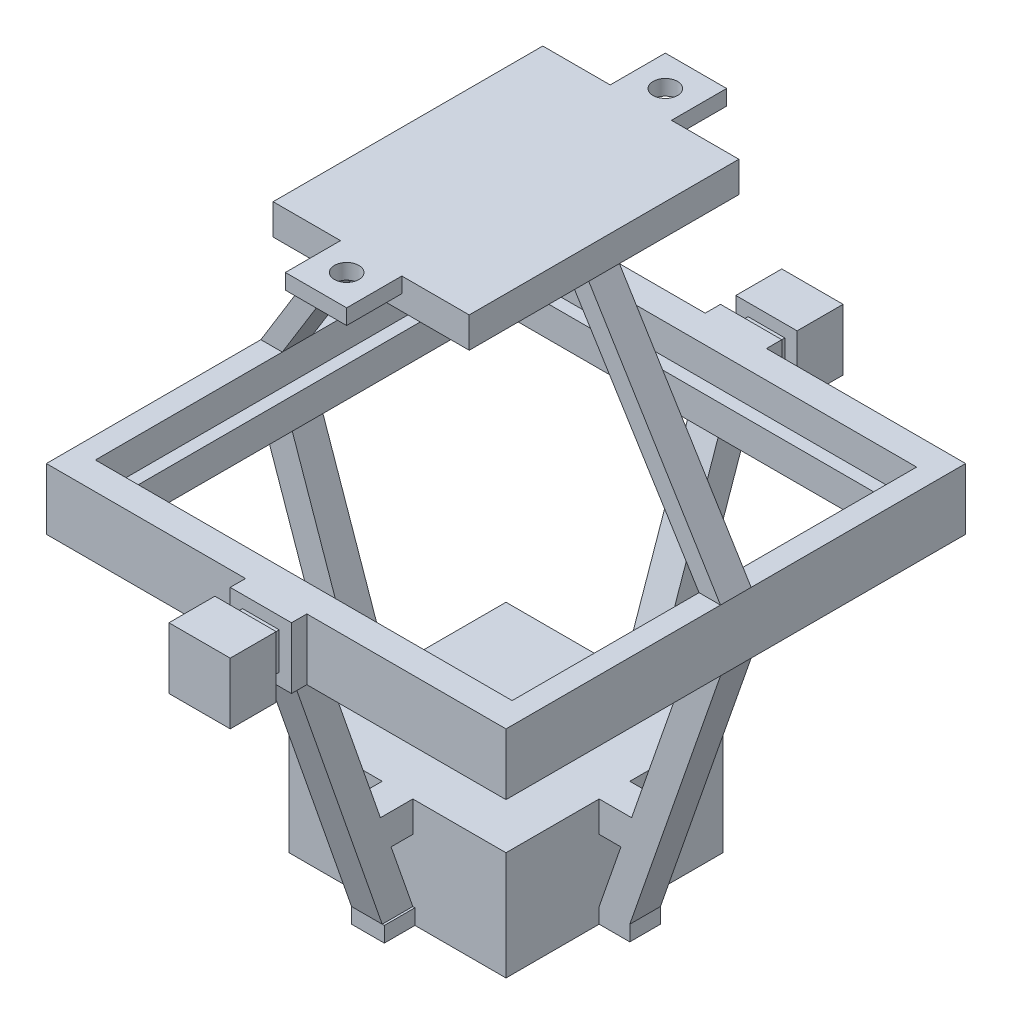
from build123d import *

# Parameters (mm, degrees)
SKETCH2_W                   = 75
SKETCH2_H                   = 75
BOSS_EXTRUDE1_DEPTH         = 5
SKETCH2_2_W                 = 75
SKETCH2_2_H                 = 75
BOSS_EXTRUDE2_DEPTH         = 5
SKETCH4_W                   = 68
SKETCH4_H                   = 66
CUT_EXTRUDE1_DEPTH          = 5
SKETCH5_W                   = 64
SKETCH5_H                   = 62
CUT_EXTRUDE2_DEPTH          = 5
SKETCH6_W                   = 10
SKETCH6_H                   = 10
BOSS_EXTRUDE3_DEPTH         = 2.5
SKETCH7_W                   = 6
SKETCH7_H                   = 6
BOSS_EXTRUDE4_DEPTH         = 2.5
SKETCH8_W                   = 10
SKETCH8_H                   = 10
BOSS_EXTRUDE5_DEPTH         = 7.5
SKETCH9_W                   = 10
SKETCH9_H                   = 10
BOSS_EXTRUDE6_DEPTH         = 2.5
SKETCH10_W                  = 6
SKETCH10_H                  = 6
BOSS_EXTRUDE7_DEPTH         = 2.5
SKETCH11_W                  = 10
SKETCH11_H                  = 10
BOSS_EXTRUDE8_DEPTH         = 7.5
SKETCH14_W                  = 35.4
SKETCH14_H                  = 35.4
BOSS_EXTRUDE9_DEPTH         = 17.7
SKETCH15_W                  = 25.4
SKETCH15_H                  = 25.4
CUT_EXTRUDE3_DEPTH          = 12.7
SKETCH32_R                  = 3
CUT_EXTRUDE6_DEPTH          = 5
SKETCH16_W                  = 32
SKETCH16_H                  = 44
BOSS_EXTRUDE10_DEPTH        = 5
SKETCH18_W                  = 10
SKETCH18_H                  = 9
BOSS_EXTRUDE12_DEPTH        = 2.5
BOSS_EXTRUDE13_DEPTH        = 2.5
BOSS_EXTRUDE14_DEPTH        = 2.5
SKETCH31_R                  = 2
CHARGER_SUPPORT_HOLES_DEPTH = 2.5
SKETCH27_W                  = 5
SKETCH27_H                  = 5
SKETCH27_W_2                = 5.344431893
EYEBOLT_BOLT_SUPPORTS_DEPTH = 2.5
BOSS_EXTRUDE15_DEPTH        = 2.5
BOSS_EXTRUDE16_DEPTH        = 2.5
BOSS_EXTRUDE17_DEPTH        = 2.5
BOSS_EXTRUDE18_DEPTH        = 2.5
SKETCH33_W                  = 6.3
SKETCH33_H                  = 5
SKETCH33_W_2                = 5
SKETCH33_H_2                = 6.3
EYEBOLT_MINI_SUPPORTS_DEPTH = 5


with BuildPart() as part:
    # Sketch2 → Boss-Extrude1 (new body)
    with BuildSketch(Plane(origin=(0, 0, 0), x_dir=(1, 0, 0), z_dir=(0, 1, 0))):
        Rectangle(SKETCH2_W, SKETCH2_H)
    extrude(amount=BOSS_EXTRUDE1_DEPTH)

    # Sketch2_2 → Boss-Extrude2 (add)
    with BuildSketch(Plane(origin=(0, 0, 0), x_dir=(1, 0, 0), z_dir=(0, 1, 0))):
        Rectangle(SKETCH2_2_W, SKETCH2_2_H)
    extrude(amount=-BOSS_EXTRUDE2_DEPTH)

    # Sketch4 → Cut-Extrude1 (cut)
    with BuildSketch(Plane(origin=(0, 5, 0), x_dir=(1, 0, 0), z_dir=(0, 1, 0))):
        Rectangle(SKETCH4_W, SKETCH4_H)
    extrude(amount=-CUT_EXTRUDE1_DEPTH, mode=Mode.SUBTRACT)

    # Sketch5 → Cut-Extrude2 (cut)
    with BuildSketch(Plane(origin=(0, 0, 0), x_dir=(1, 0, 0), z_dir=(0, 1, 0))):
        Rectangle(SKETCH5_W, SKETCH5_H)
    extrude(amount=-CUT_EXTRUDE2_DEPTH, mode=Mode.SUBTRACT)

    # Sketch6 → Boss-Extrude3 (add)
    with BuildSketch(Plane.XY.offset(37.5)):
        Rectangle(SKETCH6_W, SKETCH6_H)
    extrude(amount=BOSS_EXTRUDE3_DEPTH)

    # Sketch7 → Boss-Extrude4 (add)
    with BuildSketch(Plane.XY.offset(40)):
        Rectangle(SKETCH7_W, SKETCH7_H)
    extrude(amount=BOSS_EXTRUDE4_DEPTH)

    # Sketch8 → Boss-Extrude5 (add)
    with BuildSketch(Plane.XY.offset(42.5)):
        Rectangle(SKETCH8_W, SKETCH8_H)
    extrude(amount=BOSS_EXTRUDE5_DEPTH)

    # Sketch9 → Boss-Extrude6 (add)
    with BuildSketch(Plane(origin=(0, 0, -37.5), x_dir=(-1, 0, 0), z_dir=(0, 0, -1))):
        Rectangle(SKETCH9_W, SKETCH9_H)
    extrude(amount=BOSS_EXTRUDE6_DEPTH)

    # Sketch10 → Boss-Extrude7 (add)
    with BuildSketch(Plane(origin=(0, 0, -40), x_dir=(-1, 0, 0), z_dir=(0, 0, -1))):
        Rectangle(SKETCH10_W, SKETCH10_H)
    extrude(amount=BOSS_EXTRUDE7_DEPTH)

    # Sketch11 → Boss-Extrude8 (add)
    with BuildSketch(Plane(origin=(0, 0, -42.5), x_dir=(-1, 0, 0), z_dir=(0, 0, -1))):
        Rectangle(SKETCH11_W, SKETCH11_H)
    extrude(amount=BOSS_EXTRUDE8_DEPTH)



with BuildPart() as body_2:
    # Sketch14 → Boss-Extrude9 (new body)
    with BuildSketch(Plane(origin=(0, -50, 0), x_dir=(1, 0, 0), z_dir=(0, 1, 0))):
        Rectangle(SKETCH14_W, SKETCH14_H)
    extrude(amount=BOSS_EXTRUDE9_DEPTH)

    # Sketch15 → Cut-Extrude3 (cut)
    with BuildSketch(Plane.XZ.offset(50)):
        Rectangle(SKETCH15_W, SKETCH15_H)
    extrude(amount=-CUT_EXTRUDE3_DEPTH, mode=Mode.SUBTRACT)

    # Sketch32 → Cut-Extrude6 (cut)
    with BuildSketch(Plane(origin=(0, -32.3, 0), x_dir=(1, 0, 0), z_dir=(0, 1, 0))):
        Circle(SKETCH32_R)
    extrude(amount=-CUT_EXTRUDE6_DEPTH, mode=Mode.SUBTRACT)

    # Sketch27 → Eyebolt Bolt Supports (add)
    with BuildSketch(Plane(origin=(0, -50, 0), x_dir=(-1, 0, 0), z_dir=(0, -1, 0))):
        with Locations((-20.2, 0)):
            Rectangle(SKETCH27_W, SKETCH27_H)
        with Locations((20.2, 0)):
            Rectangle(SKETCH27_W, SKETCH27_H)
        with Locations((-0.172215947, -20.2)):
            Rectangle(SKETCH27_W_2, SKETCH27_H)
        with Locations((0, 20.2)):
            Rectangle(SKETCH27_W, SKETCH27_H)
    extrude(amount=-EYEBOLT_BOLT_SUPPORTS_DEPTH)


with BuildPart() as body_3:
    # Sketch16 → Boss-Extrude10 (new body)
    with BuildSketch(Plane(origin=(0, 45, 0), x_dir=(1, 0, 0), z_dir=(0, 1, 0))):
        Rectangle(SKETCH16_W, SKETCH16_H)
    extrude(amount=-BOSS_EXTRUDE10_DEPTH)

    # Sketch18 → Boss-Extrude12 (add)
    with BuildSketch(Plane(origin=(0, 45, 0), x_dir=(1, 0, 0), z_dir=(0, 1, 0))):
        with Locations((0, 26.5)):
            Rectangle(SKETCH18_W, SKETCH18_H)
        with Locations((0, -26.5)):
            Rectangle(SKETCH18_W, SKETCH18_H)
    extrude(amount=-BOSS_EXTRUDE12_DEPTH)


with BuildPart() as part_1:
    add(part.part)

    add(body_3.part)  # Boss-Extrude13 merges body 3
    # Sketch21 → Boss-Extrude13 (add)
    with BuildSketch(Plane.XY):
        Polygon((-37.5, 5), (-34, 5), (-12.434815796, 40), (-16, 40), align=None)
        Polygon((37.5, 5), (34, 5), (12.245590879, 40), (16, 40), align=None)
    extrude(amount=BOSS_EXTRUDE13_DEPTH)

    # Sketch21_2 → Boss-Extrude14 (add)
    with BuildSketch(Plane.XY):
        Polygon((-37.5, 5), (-34, 5), (-12.434815796, 40), (-16, 40), align=None)
        Polygon((37.5, 5), (34, 5), (12.245590879, 40), (16, 40), align=None)
    extrude(amount=-BOSS_EXTRUDE14_DEPTH)

    # Sketch31 → Charger Support Holes (cut)
    with BuildSketch(Plane(origin=(0, 45, 0), x_dir=(1, 0, 0), z_dir=(0, 1, 0))):
        with Locations((0, 26)):
            Circle(SKETCH31_R)
        with Locations((0, -26)):
            Circle(SKETCH31_R)
    extrude(amount=-CHARGER_SUPPORT_HOLES_DEPTH, mode=Mode.SUBTRACT)


    add(body_2.part)  # Boss-Extrude15 merges body 2
    # Sketch28 → Boss-Extrude15 (add)
    with BuildSketch(Plane.XY):
        Polygon((22.7, -47.5), (37.5, -5), (32.5, -5), (17.7, -47.5), align=None)
        Polygon((-22.7, -47.5), (-37.5, -5), (-32.5, -5), (-17.7, -47.5), align=None)
    extrude(amount=BOSS_EXTRUDE15_DEPTH)

    # Sketch28_2 → Boss-Extrude16 (add)
    with BuildSketch(Plane.XY):
        Polygon((22.7, -47.5), (37.5, -5), (32.5, -5), (17.7, -47.5), align=None)
        Polygon((-22.7, -47.5), (-37.5, -5), (-32.5, -5), (-17.7, -47.5), align=None)
    extrude(amount=-BOSS_EXTRUDE16_DEPTH)

    # Sketch30 → Boss-Extrude17 (add)
    with BuildSketch(Plane(origin=(0, 0, 0), x_dir=(0, 0, -1), z_dir=(1, 0, 0))):
        Polygon((22.7, -47.5), (37.5, -5), (32.5, -5), (17.7, -47.5), align=None)
        Polygon((-37.5, -5), (-22.7, -47.5), (-17.7, -47.5), (-32.5, -5), align=None)
    extrude(amount=BOSS_EXTRUDE17_DEPTH)

    # Sketch30_2 → Boss-Extrude18 (add)
    with BuildSketch(Plane(origin=(0, 0, 0), x_dir=(0, 0, -1), z_dir=(1, 0, 0))):
        Polygon((22.7, -47.5), (37.5, -5), (32.5, -5), (17.7, -47.5), align=None)
        Polygon((-37.5, -5), (-22.7, -47.5), (-17.7, -47.5), (-32.5, -5), align=None)
    extrude(amount=-BOSS_EXTRUDE18_DEPTH)

    # Sketch33 → Eyebolt Mini Supports (add)
    with BuildSketch(Plane(origin=(0, -32.3, 0), x_dir=(1, 0, 0), z_dir=(0, 1, 0))):
        with Locations((20.85, 0)):
            Rectangle(SKETCH33_W, SKETCH33_H)
        with Locations((0, 20.85)):
            Rectangle(SKETCH33_W_2, SKETCH33_H_2)
        with Locations((-20.85, 0)):
            Rectangle(SKETCH33_W, SKETCH33_H)
        with Locations((0, -20.85)):
            Rectangle(SKETCH33_W_2, SKETCH33_H_2)
    extrude(amount=-EYEBOLT_MINI_SUPPORTS_DEPTH)


solid = part_1.part
